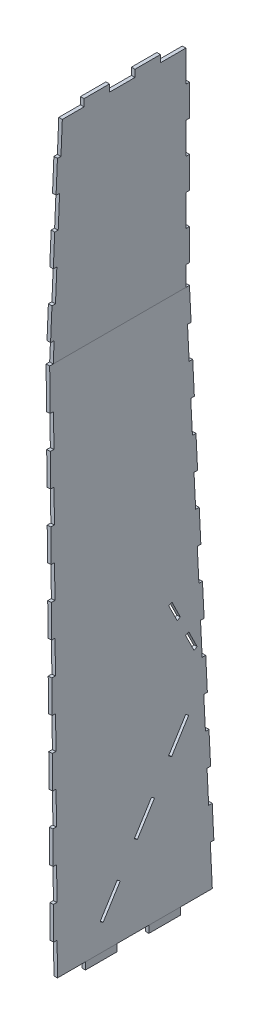
from build123d import *

# Parameters (mm, degrees)
SKETCH1_W                = 10.166490401
SKETCH1_H                = 20.32
BOSS_EXTRUDE1_DEPTH      = 450.605251
BOSS_EXTRUDE1_DEPTH_BACK = 10.16
SKETCH2_W                = 40.64
SKETCH2_H                = 88.420284457
CUT_EXTRUDE1_DEPTH       = 1125.982
SKETCH4_W                = 10.16
SKETCH4_H                = 20.292482061
SKETCH4_H_2              = 111.176423169
SKETCH4_H_3              = 88.9
CUT_EXTRUDE2_DEPTH       = 2108.968119463
CUT_EXTRUDE3_REACH       = 2123.564
SKETCH5_W                = 10.16
SKETCH5_H                = 88.9
SKETCH5_H_2              = 55.879999965
SKETCH6_W                = 89.925250809
SKETCH6_H                = 20.32
SKETCH6_W_2              = 90.17
CUT_EXTRUDE4_DEPTH       = 1125.982
SKETCH7_W                = 82.55
SKETCH7_H                = 20.32
SKETCH7_W_2              = 72.39
CUT_EXTRUDE5_DEPTH       = 1125.982
CUT_EXTRUDE6_DEPTH       = 2108.139004111


with BuildPart() as part:
    # Sketch1 → Boss-Extrude1 (new, two sides)
    with BuildSketch(Plane.XY) as boss_extrude1_sk:
        Polygon((291.041413739, 20.32), (280.874923338, 20.32), (205.715298803, 1463.040000035), (205.715298803, 2052.32), (215.881789204, 2052.32), (215.881789204, 1463.040000035), align=None)
        with Locations((285.958168538, 10.16)):
            Rectangle(SKETCH1_W, SKETCH1_H)
        with Locations((210.798544004, 2062.48)):
            Rectangle(SKETCH1_W, SKETCH1_H)
    extrude(amount=BOSS_EXTRUDE1_DEPTH)
    extrude(boss_extrude1_sk.sketch, amount=-BOSS_EXTRUDE1_DEPTH_BACK)

    # Sketch2 → Cut-Extrude1 (cut)
    with BuildSketch(Plane(origin=(605.264675653, -1278.915479685, -1125.851113248), x_dir=(0, -1, 0), z_dir=(-1, 0, 0))):
        Polygon((-3310.915479685, 1576.456364056), (-3310.915479685, 1488.036079599), (-1299.235479685, 1576.456364056), align=None)
        with Locations((-3331.235479685, 1532.246221827)):
            Rectangle(SKETCH2_W, SKETCH2_H)
    extrude(amount=CUT_EXTRUDE1_DEPTH, mode=Mode.SUBTRACT)

    # Sketch4 → Cut-Extrude2 (cut, through all)
    with BuildSketch(Plane(origin=(291.309394939, 15.175990314, 0), x_dir=(0, 0, -1), z_dir=(0.9986457707048434, 0.05202523093009139, 0))):
        with Locations((5.08, -4.99525573)):
            Rectangle(SKETCH4_W, SKETCH4_H)
        with Locations((5.08, 60.739196886)):
            Rectangle(SKETCH4_W, SKETCH4_H_2)
        with Locations((5.08, 249.67740847)):
            Rectangle(SKETCH4_W, SKETCH4_H_3)
        with Locations((5.08, 783.07740847)):
            Rectangle(SKETCH4_W, SKETCH4_H_3)
        with Locations((5.08, 960.87740847)):
            Rectangle(SKETCH4_W, SKETCH4_H_3)
        with Locations((5.08, 1138.67740847)):
            Rectangle(SKETCH4_W, SKETCH4_H_3)
        with Locations((5.08, 1316.47740847)):
            Rectangle(SKETCH4_W, SKETCH4_H_3)
        with Locations((-445.525250809, -4.99525573)):
            Rectangle(SKETCH4_W, SKETCH4_H)
        Polygon((-450.605250809, 5.150985301), (-440.445250809, 5.150985301), (-436.546834031, 93.965468053), (-446.687296633, 94.410572819), align=None)
        Polygon((-411.601545632, 893.740917593), (-401.46108303, 893.295812828), (-397.562666252, 982.11029558), (-407.703128854, 982.555400346), align=None)
        Polygon((-403.804712076, 1071.369883099), (-393.664249474, 1070.924778333), (-389.765832696, 1159.739261086), (-399.906295298, 1160.184365851), align=None)
        Polygon((-396.00787852, 1248.998848604), (-385.867415918, 1248.553743838), (-381.96899914, 1337.368226591), (-392.109461742, 1337.813331357), align=None)
        Polygon((-419.398379188, 716.111952088), (-409.257916585, 715.666847322), (-405.359499808, 804.481330075), (-415.49996241, 804.926434841), align=None)
        Polygon((-455.140613686, 5.150985301), (-450.605250809, 5.150985301), (-446.687296633, 94.410572819), (-450.605250809, 94.410572819), align=None)
        Polygon((-449.818612929, 183.53361819), (-442.788879855, 183.225055572), (-438.890463077, 272.039538325), (-445.920196151, 272.348100943), align=None)
        Polygon((-441.625759495, 361.145200827), (-434.992046299, 360.854021077), (-431.093629521, 449.66850383), (-437.727342717, 449.959683579), align=None)
        Polygon((-434.571427919, 538.806757663), (-427.195212743, 538.482986583), (-423.296795965, 627.297469335), (-430.673011141, 627.621240415), align=None)
        Polygon((-426.54112259, 716.425475174), (-419.398379188, 716.111952088), (-415.49996241, 804.926434841), (-422.642705812, 805.239957927), align=None)
        Polygon((-420.338817864, 894.124430818), (-411.601545632, 893.740917593), (-407.703128854, 982.555400346), (-416.440401086, 982.93891357), align=None)
        Polygon((-415.276210663, 1071.873412266), (-403.804712076, 1071.369883099), (-399.906295298, 1160.184365851), (-411.377793885, 1160.687895019), align=None)
        Polygon((-414.342332906, 1249.80361988), (-396.00787852, 1248.998848604), (-392.109461742, 1337.813331357), (-410.443916128, 1338.618102632), align=None)
        with Locations((5.08, 427.47740847)):
            Rectangle(SKETCH4_W, SKETCH4_H_3)
        with Locations((5.08, 605.27740847)):
            Rectangle(SKETCH4_W, SKETCH4_H_3)
        Polygon((-442.788879855, 183.225055572), (-438.890463077, 272.039538325), (-428.750000475, 271.594433559), (-432.648417253, 182.779950806), align=None)
        Polygon((-434.992046299, 360.854021077), (-431.093629521, 449.66850383), (-420.953166919, 449.223399064), (-424.851583697, 360.408916311), align=None)
        Polygon((-417.054750141, 538.037881817), (-413.156333363, 626.852364569), (-423.296795965, 627.297469335), (-427.195212743, 538.482986583), align=None)
    extrude(amount=-CUT_EXTRUDE2_DEPTH, mode=Mode.SUBTRACT)

    # Cut-Extrude3: up to this face of the body (flat: up to its plane)
    cut_extrude3_end = Plane(part.part.faces().sort_by_distance((205.715298803, 1754.382873748, 182.121056608))[0])
    # Sketch5 → Cut-Extrude3 (cut, up to the picked face)
    with BuildSketch(Plane(origin=(215.881789204, 0, 0), x_dir=(0, 0, -1), z_dir=(1, 0, 0)), mode=Mode.PRIVATE) as cut_extrude3_sk1:
        with Locations((5.08, 2007.87)):
            Rectangle(SKETCH5_W, SKETCH5_H)
    cut_extrude3_tool1 = split(extrude(cut_extrude3_sk1.sketch, amount=-CUT_EXTRUDE3_REACH, mode=Mode.PRIVATE), bisect_by=cut_extrude3_end, keep=Keep.BOTH, mode=Mode.PRIVATE)
    # Sketch5 → Cut-Extrude3 (cut, up to the picked face)
    with BuildSketch(Plane(origin=(215.881789204, 0, 0), x_dir=(0, 0, -1), z_dir=(1, 0, 0)), mode=Mode.PRIVATE) as cut_extrude3_sk2:
        with Locations((5.08, 1830.07)):
            Rectangle(SKETCH5_W, SKETCH5_H)
    cut_extrude3_tool2 = split(extrude(cut_extrude3_sk2.sketch, amount=-CUT_EXTRUDE3_REACH, mode=Mode.PRIVATE), bisect_by=cut_extrude3_end, keep=Keep.BOTH, mode=Mode.PRIVATE)
    # Sketch5 → Cut-Extrude3 (cut, up to the picked face)
    with BuildSketch(Plane(origin=(215.881789204, 0, 0), x_dir=(0, 0, -1), z_dir=(1, 0, 0)), mode=Mode.PRIVATE) as cut_extrude3_sk3:
        with Locations((5.08, 1652.27)):
            Rectangle(SKETCH5_W, SKETCH5_H)
    cut_extrude3_tool3 = split(extrude(cut_extrude3_sk3.sketch, amount=-CUT_EXTRUDE3_REACH, mode=Mode.PRIVATE), bisect_by=cut_extrude3_end, keep=Keep.BOTH, mode=Mode.PRIVATE)
    # Sketch5 → Cut-Extrude3 (cut, up to the picked face)
    with BuildSketch(Plane(origin=(215.881789204, 0, 0), x_dir=(0, 0, -1), z_dir=(1, 0, 0)), mode=Mode.PRIVATE) as cut_extrude3_sk4:
        with Locations((5.08, 1490.980000018)):
            Rectangle(SKETCH5_W, SKETCH5_H_2)
    cut_extrude3_tool4 = split(extrude(cut_extrude3_sk4.sketch, amount=-CUT_EXTRUDE3_REACH, mode=Mode.PRIVATE), bisect_by=cut_extrude3_end, keep=Keep.BOTH, mode=Mode.PRIVATE)
    # Sketch5 → Cut-Extrude3 (cut, up to the picked face)
    with BuildSketch(Plane(origin=(215.881789204, 0, 0), x_dir=(0, 0, -1), z_dir=(1, 0, 0)), mode=Mode.PRIVATE) as cut_extrude3_sk5:
        Polygon((-355.231442512, 1962.99930346), (-351.338294917, 2051.814017969), (-361.488468688, 2052.260153165), (-362.184966352, 2036.370891417), (-362.184966352, 2032), (-365.19852982, 1963.437391374), align=None)
    cut_extrude3_tool5 = split(extrude(cut_extrude3_sk5.sketch, amount=-CUT_EXTRUDE3_REACH, mode=Mode.PRIVATE), bisect_by=cut_extrude3_end, keep=Keep.BOTH, mode=Mode.PRIVATE)
    # Sketch5 → Cut-Extrude3 (cut, up to the picked face)
    with BuildSketch(Plane(origin=(215.881789204, 0, 0), x_dir=(0, 0, -1), z_dir=(1, 0, 0)), mode=Mode.PRIVATE) as cut_extrude3_sk6:
        Polygon((-363.017737701, 1785.369874443), (-359.124590106, 1874.184588952), (-369.102222921, 1874.623140377), (-373.005916021, 1785.80888938), align=None)
    cut_extrude3_tool6 = split(extrude(cut_extrude3_sk6.sketch, amount=-CUT_EXTRUDE3_REACH, mode=Mode.PRIVATE), bisect_by=cut_extrude3_end, keep=Keep.BOTH, mode=Mode.PRIVATE)
    # Sketch5 → Cut-Extrude3 (cut, up to the picked face)
    with BuildSketch(Plane(origin=(215.881789204, 0, 0), x_dir=(0, 0, -1), z_dir=(1, 0, 0)), mode=Mode.PRIVATE) as cut_extrude3_sk7:
        Polygon((-387.19272357, 1463.040000035), (-377.14690292, 1463.040000035), (-374.697180484, 1518.925730918), (-384.716995324, 1519.366136389), align=None)
    cut_extrude3_tool7 = split(extrude(cut_extrude3_sk7.sketch, amount=-CUT_EXTRUDE3_REACH, mode=Mode.PRIVATE), bisect_by=cut_extrude3_end, keep=Keep.BOTH, mode=Mode.PRIVATE)
    # Sketch5 → Cut-Extrude3 (cut, up to the picked face)
    with BuildSketch(Plane(origin=(215.881789204, 0, 0), x_dir=(0, 0, -1), z_dir=(1, 0, 0)), mode=Mode.PRIVATE) as cut_extrude3_sk8:
        Polygon((-370.80403289, 1607.740445426), (-366.910885295, 1696.555159935), (-376.909609122, 1696.994638383), (-380.813302223, 1608.180387386), align=None)
    cut_extrude3_tool8 = split(extrude(cut_extrude3_sk8.sketch, amount=-CUT_EXTRUDE3_REACH, mode=Mode.PRIVATE), bisect_by=cut_extrude3_end, keep=Keep.BOTH, mode=Mode.PRIVATE)
    add(cut_extrude3_tool1.solids().sort_by(Axis((215.881789, 2007.87, -5.08), (-1, 0, 0)))[0], mode=Mode.SUBTRACT)
    add(cut_extrude3_tool2.solids().sort_by(Axis((215.881789, 1830.07, -5.08), (-1, 0, 0)))[0], mode=Mode.SUBTRACT)
    add(cut_extrude3_tool3.solids().sort_by(Axis((215.881789, 1652.27, -5.08), (-1, 0, 0)))[0], mode=Mode.SUBTRACT)
    add(cut_extrude3_tool4.solids().sort_by(Axis((215.881789, 1490.98, -5.08), (-1, 0, 0)))[0], mode=Mode.SUBTRACT)
    add(cut_extrude3_tool5.solids().sort_by(Axis((215.881789, 2007.75713, 358.279909), (-1, 0, 0)))[0], mode=Mode.SUBTRACT)
    add(cut_extrude3_tool6.solids().sort_by(Axis((215.881789, 1829.988805, 366.06296), (-1, 0, 0)))[0], mode=Mode.SUBTRACT)
    add(cut_extrude3_tool7.solids().sort_by(Axis((215.881789, 1491.090003, 380.945152), (-1, 0, 0)))[0], mode=Mode.SUBTRACT)
    add(cut_extrude3_tool8.solids().sort_by(Axis((215.881789, 1652.359856, 373.8598), (-1, 0, 0)))[0], mode=Mode.SUBTRACT)

    # Sketch6 → Cut-Extrude4 (cut)
    with BuildSketch(Plane(origin=(291.041413739, 0, 0), x_dir=(0, 0, -1), z_dir=(1, 0, 0))):
        with Locations((-405.642625404, 10.16)):
            Rectangle(SKETCH6_W, SKETCH6_H)
        with Locations((-225.425, 10.16)):
            Rectangle(SKETCH6_W_2, SKETCH6_H)
        with Locations((-45.085, 10.16)):
            Rectangle(SKETCH6_W_2, SKETCH6_H)
    extrude(amount=-CUT_EXTRUDE4_DEPTH, mode=Mode.SUBTRACT)

    # Sketch7 → Cut-Extrude5 (cut)
    with BuildSketch(Plane(origin=(215.881789204, 0, 0), x_dir=(0, 0, -1), z_dir=(1, 0, 0))):
        with Locations((-31.115, 2062.48)):
            Rectangle(SKETCH7_W, SKETCH7_H)
        with Locations((-180.975, 2062.48)):
            Rectangle(SKETCH7_W_2, SKETCH7_H)
        Polygon((-351.338294917, 2051.814017969), (-351.316115454, 2052.32), (-289.56, 2052.32), (-289.56, 2072.64), (-362.184966352, 2072.64), (-362.184966352, 2036.370891417), (-361.488468688, 2052.260153165), align=None)
    extrude(amount=-CUT_EXTRUDE5_DEPTH, mode=Mode.SUBTRACT)

    # Sketch9 → Cut-Extrude6 (cut, through all)
    with BuildSketch(Plane(origin=(291.309394939, 15.175990314, 0), x_dir=(0, 0, -1), z_dir=(0.9986457707048444, 0.05202523093007474, 0))):
        Polygon((-96.800454295, 369.477574692), (-44.256814481, 443.449817787), (-52.543639813, 449.336079272), (-105.087279627, 375.363836176), align=None)
        Polygon((-201.887733921, 221.533088501), (-149.344094108, 295.505331596), (-157.63091944, 301.39159308), (-210.174559253, 227.419349985), align=None)
        Polygon((-306.975013548, 73.588602309), (-254.431373734, 147.560845405), (-262.718199066, 153.447106889), (-315.26183888, 79.474863794), align=None)
        Polygon((-21.7668071, 588.218839028), (-12.554964696, 592.51040284), (-34.07199968, 638.696721847), (-43.283842083, 634.405158034), align=None)
        Polygon((-55.589034664, 684.883040853), (-77.106069648, 731.069359859), (-86.317912051, 726.777796047), (-64.800877067, 680.591477041), align=None)
    extrude(amount=-CUT_EXTRUDE6_DEPTH, mode=Mode.SUBTRACT)


solid = part.part
